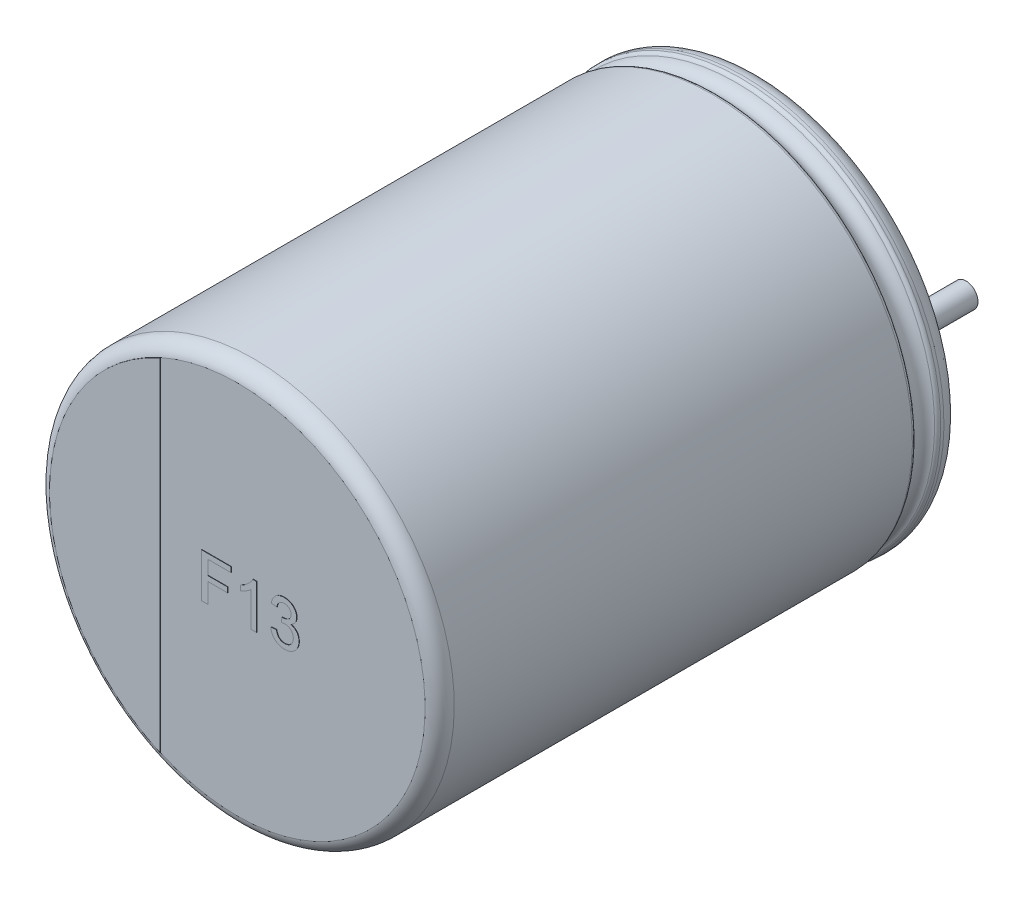
from build123d import *

# Parameters (mm, degrees)
SKETCH_2_R         = 0.3
EXTRUDE_1_DEPTH    = 2.7
EXTRUDE_2_DEPTH    = 0.01
EXTRUDE_1820_DEPTH = 0.01
EXTRUDE_5_DEPTH    = 0.05


with BuildPart() as part:
    # Sketch10 → Повернуть1 (revolve)
    with BuildSketch(Plane(origin=(0, 0, 0), x_dir=(0, 0, -1), z_dir=(1, 0, 0))):
        with BuildLine():
            Line((-13, 0), (-0.05, 0))
            Line((-0.05, 0), (-0.05, 4.403143426))
            ThreePointArc((-0.05, 4.403143426), (-0.052704561, 4.801565585), (-0.398206102, 5))
            Line((-0.398206102, 5), (-0.479422929, 5))
            ThreePointArc((-0.479422929, 5), (-0.534479696, 4.983479053), (-0.571344666, 4.939375046))
            ThreePointArc((-0.571344666, 4.939375046), (-0.831990181, 4.767472047), (-1.092635697, 4.939375046))
            ThreePointArc((-1.092635697, 4.939375046), (-1.129500666, 4.983479053), (-1.184557434, 5))
            Line((-1.184557434, 5), (-12.6, 5))
            ThreePointArc((-12.6, 5), (-12.85971595, 4.909961924), (-13, 4.67357323))
            Line((-13, 4.67357323), (-13, 0))
        make_face()
    revolve(axis=Axis((0, 0, -18.1630778), (0, 0, 1)))

    # Эскиз2 → Бобышка-Вытянуть1 (add)
    with BuildSketch(Plane(origin=(0, 0, 0.05), x_dir=(-1, 0, 0), z_dir=(0, 0, -1))):
        with Locations(Location((-2.5, 0, 0), (0, 0, 90))):
            Circle(SKETCH_2_R)
        with Locations(Location((2.5, 0, 0), (0, 0, 270))):
            Circle(SKETCH_2_R)
    extrude(amount=EXTRUDE_1_DEPTH)

    # Эскиз4 → Бобышка-Вытянуть2 (add)
    with BuildSketch(Plane.XY.offset(13)):
        with BuildLine():
            Line((-1.920580247, -4.260711003), (-1.920580247, 4.260711003))
            ThreePointArc((-1.920580247, 4.260711003), (-4.67357323, 0), (-1.920580247, -4.260711003))
        make_face()
    extrude(amount=EXTRUDE_2_DEPTH)

    # Эскиз5 → Extrude 1820 (add)
    with BuildSketch(Plane.XY.offset(13)):
        Polygon((-0.884369756, -0.464160183), (-0.884369756, 0.635839817), (-0.151036423, 0.635839817), (-0.151036423, 0.50891674), (-0.729241551, 0.50891674), (-0.729241551, 0.156352638), (-0.235651808, 0.156352638), (-0.235651808, 0.029429561), (-0.729241551, 0.029429561), (-0.729241551, -0.464160183), align=None)
        with BuildLine():
            Line((0.483578962, -0.464160183), (0.342553321, -0.464160183))
            Line((0.342553321, -0.464160183), (0.342553321, 0.393011291))
            add(Edge.make_bspline(
                [(0.342553321, 0.393011291), (0.334433052, 0.385180291), (0.317555963, 0.368904415), (0.289027027, 0.345869987), (0.257185088, 0.322523617), (0.222443635, 0.300073472), (0.187030601, 0.278939082), (0.152808462, 0.259931947), (0.120348573, 0.2438473), (0.098967068, 0.235052151), (0.088707167, 0.230831804)],
                knots=[0, 0, 0, 0, 0.893362401, 1.856755847, 2.901947673, 4.020460078, 5.132200827, 6.168787962, 7.121294059, 8, 8, 8, 8], degree=3))
            Line((0.088707167, 0.230831804), (0.088707167, 0.360839817))
            add(Edge.make_bspline(
                [(0.088707167, 0.360839817), (0.106329608, 0.369915409), (0.141062395, 0.387802865), (0.190132314, 0.418696959), (0.235944361, 0.452187428), (0.277740167, 0.488266859), (0.315207443, 0.525146514), (0.346781661, 0.562359534), (0.373200957, 0.598541851), (0.386456019, 0.623775005), (0.392793705, 0.635839817)],
                knots=[0, 0, 0, 0, 1.141258006, 2.249351951, 3.335817539, 4.406819942, 5.426913362, 6.360259544, 7.215985427, 8, 8, 8, 8], degree=3))
            Line((0.392793705, 0.635839817), (0.483578962, 0.635839817))
            Line((0.483578962, 0.635839817), (0.483578962, -0.464160183))
        make_face()
        with BuildLine():
            Line((0.836143064, -0.168006337), (0.977168705, -0.153903773))
            add(Edge.make_bspline(
                [(0.977168705, -0.153903773), (0.979048746, -0.162377428), (0.982686485, -0.178773324), (0.98968594, -0.202262147), (0.997078901, -0.224065027), (1.006243912, -0.243694287), (1.015186971, -0.261952681), (1.025696419, -0.278085789), (1.036925968, -0.292514547), (1.049083215, -0.305185376), (1.062308251, -0.316096508), (1.076424756, -0.325644336), (1.091731282, -0.333618059), (1.108110637, -0.339931304), (1.125424869, -0.345041929), (1.143768071, -0.348794569), (1.16323724, -0.351030063), (1.176581775, -0.351234784), (1.183418705, -0.35133967)],
                knots=[0, 0, 0, 0, 1.321063709, 2.556160278, 3.730472002, 4.821700466, 5.852032229, 6.822994757, 7.746964065, 8.632786469, 9.490489437, 10.352773447, 11.223141997, 12.11199479, 13.021433979, 13.96892724, 14.959401504, 16, 16, 16, 16], degree=3))
            add(Edge.make_bspline(
                [(1.183418705, -0.35133967), (1.191438182, -0.351225332), (1.207100233, -0.351002029), (1.229922425, -0.347651632), (1.251641766, -0.343051218), (1.271948377, -0.335837506), (1.291125017, -0.327021016), (1.309062437, -0.316125705), (1.325883416, -0.303331883), (1.341256172, -0.288552526), (1.35500399, -0.272294762), (1.367248354, -0.255122414), (1.377372798, -0.236888955), (1.385906179, -0.217851209), (1.392204931, -0.197701536), (1.396816125, -0.176691191), (1.399829565, -0.154725157), (1.400105037, -0.139737851), (1.400245628, -0.132088869)],
                knots=[0, 0, 0, 0, 1.111377895, 2.170522867, 3.193923215, 4.186422864, 5.152846954, 6.117443035, 7.091571248, 8.078879332, 9.069127402, 10.041602243, 10.999610288, 11.957618333, 12.930786866, 13.922135183, 14.939532534, 16, 16, 16, 16], degree=3))
            add(Edge.make_bspline(
                [(1.400245628, -0.132088869), (1.400080392, -0.124809694), (1.399757121, -0.11056857), (1.397099572, -0.089665655), (1.392462206, -0.06982315), (1.386033709, -0.050926221), (1.377819409, -0.033002608), (1.367946062, -0.015904101), (1.35587015, -5.414e-06), (1.342277646, 0.014864219), (1.327452189, 0.028563417), (1.311228004, 0.040216348), (1.294154064, 0.050273208), (1.276026886, 0.058393729), (1.256921736, 0.064839032), (1.236856826, 0.069471399), (1.215735689, 0.072130102), (1.201348232, 0.072453429), (1.193995628, 0.072618663)],
                knots=[0, 0, 0, 0, 1.072815875, 2.098878726, 3.09954706, 4.07199174, 5.036203424, 6.001873089, 6.97636515, 7.972747947, 8.969130744, 9.945905975, 10.911575641, 11.885646534, 12.868345115, 13.879560892, 14.916365174, 16, 16, 16, 16], degree=3))
            add(Edge.make_bspline(
                [(1.193995628, 0.072618663), (1.187522107, 0.072447159), (1.173783786, 0.072083188), (1.152100118, 0.068869458), (1.128081783, 0.064369483), (1.111484428, 0.059953425), (1.102769667, 0.057634689)],
                knots=[0, 0, 0, 0, 0.837610211, 1.777604146, 2.833088267, 4, 4, 4, 4], degree=3))
            Line((1.102769667, 0.057634689), (1.117312936, 0.184557766))
            add(Edge.make_bspline(
                [(1.117312936, 0.184557766), (1.12112875, 0.184140802), (1.127869979, 0.183404169), (1.134645204, 0.183132982), (1.137585372, 0.183015298)],
                knots=[0, 0, 0, 0, 1.132082448, 2, 2, 2, 2], degree=3))
            add(Edge.make_bspline(
                [(1.137585372, 0.183015298), (1.150555061, 0.183510476), (1.175997514, 0.184481859), (1.213087678, 0.192553238), (1.248238275, 0.205261365), (1.275394382, 0.220424003), (1.295532433, 0.234685288), (1.308231084, 0.24754386), (1.319679572, 0.261189402), (1.32822108, 0.276841333), (1.335600416, 0.293471887), (1.340170053, 0.311736188), (1.343502606, 0.331190275), (1.343722458, 0.344664705), (1.343835372, 0.351585009)],
                knots=[0, 0, 0, 0, 1.557468908, 3.055264441, 4.54122591, 6.035034992, 6.780215604, 7.498173296, 8.201377046, 8.913174237, 9.633083494, 10.382644491, 11.169345745, 12, 12, 12, 12], degree=3))
            add(Edge.make_bspline(
                [(1.343835372, 0.351585009), (1.343731161, 0.357174773), (1.343527354, 0.368106772), (1.341256851, 0.384134239), (1.337501717, 0.399320756), (1.332426281, 0.413828476), (1.325774418, 0.427581365), (1.317525585, 0.440562586), (1.308101014, 0.453035475), (1.296975642, 0.464355514), (1.285061333, 0.474983349), (1.271923622, 0.483934166), (1.258187765, 0.491885651), (1.243369331, 0.497894218), (1.227834152, 0.502834239), (1.21144943, 0.506296005), (1.194209186, 0.508620814), (1.182398379, 0.50881671), (1.176367423, 0.50891674)],
                knots=[0, 0, 0, 0, 1.041493611, 2.036867705, 3.009952345, 3.954088258, 4.897230656, 5.850851638, 6.817653571, 7.805463921, 8.805067469, 9.788883576, 10.763797054, 11.758134544, 12.762883247, 13.799594994, 14.876406454, 16, 16, 16, 16], degree=3))
            add(Edge.make_bspline(
                [(1.176367423, 0.50891674), (1.164564994, 0.508456544), (1.141772755, 0.507567837), (1.109140746, 0.499345454), (1.079570255, 0.486040568), (1.057677688, 0.470437651), (1.042132041, 0.45552038), (1.031513541, 0.442876273), (1.022015894, 0.42891349), (1.013612183, 0.413637011), (1.006415943, 0.396985397), (0.999928733, 0.379164938), (0.99490703, 0.359890328), (0.992503734, 0.346534924), (0.991271269, 0.339685971)],
                knots=[0, 0, 0, 0, 1.533565899, 2.961543033, 4.347411787, 5.731829577, 6.434842101, 7.147085226, 7.87612511, 8.629021686, 9.412189982, 10.234506416, 11.094615066, 12, 12, 12, 12], degree=3))
            Line((0.991271269, 0.339685971), (0.850245628, 0.353788535))
            add(Edge.make_bspline(
                [(0.850245628, 0.353788535), (0.85245169, 0.364692791), (0.856779055, 0.386082348), (0.865595305, 0.416974696), (0.876346613, 0.445973814), (0.889255365, 0.472946746), (0.90371171, 0.498216295), (0.920388154, 0.521482725), (0.938893715, 0.542884358), (0.959261266, 0.562355915), (0.981214304, 0.579746194), (1.004642259, 0.594747591), (1.029352865, 0.607463437), (1.055369259, 0.617714658), (1.08267084, 0.626050455), (1.111335282, 0.63157294), (1.141232839, 0.635308624), (1.161591856, 0.635660574), (1.171960372, 0.635839817)],
                knots=[0, 0, 0, 0, 1.136581168, 2.229493434, 3.279335563, 4.293305329, 5.282068175, 6.250623624, 7.213783178, 8.169396253, 9.125981663, 10.071280146, 11.007896369, 11.961295906, 12.925420184, 13.920544621, 14.940967302, 16, 16, 16, 16], degree=3))
            add(Edge.make_bspline(
                [(1.171960372, 0.635839817), (1.186312866, 0.635374401), (1.214534509, 0.634459243), (1.255985525, 0.627190944), (1.295633205, 0.61526352), (1.333158505, 0.598729984), (1.367915822, 0.578526439), (1.398673182, 0.554313721), (1.425019403, 0.526510705), (1.446442765, 0.495421358), (1.463407063, 0.462320493), (1.475960133, 0.42796036), (1.483460781, 0.392380513), (1.48439332, 0.368292965), (1.484861013, 0.356212413)],
                knots=[0, 0, 0, 0, 1.104647871, 2.172094857, 3.229560912, 4.285649672, 5.322588163, 6.317201348, 7.289435229, 8.260615662, 9.214246199, 10.146367077, 11.070353327, 12, 12, 12, 12], degree=3))
            add(Edge.make_bspline(
                [(1.484861013, 0.356212413), (1.484386866, 0.344792705), (1.483450685, 0.322245037), (1.476243196, 0.289276353), (1.464063975, 0.258042232), (1.447602241, 0.228433088), (1.42625541, 0.201089242), (1.400082117, 0.176723383), (1.369501065, 0.155102367), (1.346583153, 0.143848867), (1.334800917, 0.138063375)],
                knots=[0, 0, 0, 0, 0.975609618, 1.926294443, 2.868398979, 3.832526731, 4.812148358, 5.820404151, 6.879456693, 8, 8, 8, 8], degree=3))
            add(Edge.make_bspline(
                [(1.334800917, 0.138063375), (1.34270012, 0.136068982), (1.358172353, 0.132162549), (1.380393989, 0.124068531), (1.401284822, 0.114592471), (1.421122895, 0.103859719), (1.439332271, 0.091166499), (1.456540612, 0.077287902), (1.472097402, 0.061555526), (1.486453351, 0.044530099), (1.499515501, 0.026389796), (1.510507428, 0.006781747), (1.519993142, -0.013778587), (1.528081657, -0.035440329), (1.533894046, -0.058370507), (1.538050087, -0.082391482), (1.540792735, -0.107419796), (1.541110195, -0.124516158), (1.541271269, -0.133190632)],
                knots=[0, 0, 0, 0, 1.053251915, 2.063013066, 3.05373318, 4.018979697, 4.975584284, 5.920798056, 6.874756953, 7.832116109, 8.799604348, 9.761196922, 10.734637845, 11.72654167, 12.747371341, 13.789206138, 14.878271633, 16, 16, 16, 16], degree=3))
            add(Edge.make_bspline(
                [(1.541271269, -0.133190632), (1.541002861, -0.145033375), (1.540475351, -0.168308166), (1.535474547, -0.202499364), (1.52730211, -0.235259128), (1.515992554, -0.266698705), (1.501661556, -0.296946404), (1.483678518, -0.32557538), (1.462576415, -0.352818347), (1.43868515, -0.378414463), (1.412509982, -0.401938082), (1.384084752, -0.422307287), (1.353971849, -0.439605137), (1.322122271, -0.453711448), (1.288620449, -0.464794131), (1.253433057, -0.472738552), (1.216451207, -0.47740757), (1.191217936, -0.477973936), (1.178350596, -0.478262747)],
                knots=[0, 0, 0, 0, 1.016055063, 1.996874249, 2.958724482, 3.910019225, 4.860394196, 5.826121543, 6.806008102, 7.814207964, 8.82789325, 9.821757317, 10.810247154, 11.803791187, 12.806673825, 13.834534493, 14.895752369, 16, 16, 16, 16], degree=3))
            add(Edge.make_bspline(
                [(1.178350596, -0.478262747), (1.166803227, -0.478045241), (1.14407038, -0.477617047), (1.110794186, -0.47315599), (1.078913863, -0.466825238), (1.048681501, -0.457065622), (1.019745926, -0.445163929), (0.992597201, -0.429937507), (0.966747172, -0.412458166), (0.942681139, -0.392226514), (0.920532755, -0.36989606), (0.900773747, -0.345797089), (0.883806553, -0.319983108), (0.868846645, -0.292840343), (0.856755171, -0.263857141), (0.847340044, -0.23328234), (0.840160883, -0.201229412), (0.837496909, -0.17920119), (0.836143064, -0.168006337)],
                knots=[0, 0, 0, 0, 1.08471039, 2.135426191, 3.150939737, 4.135689946, 5.116584603, 6.086901885, 7.055842759, 8.045878862, 9.036901429, 10.008421467, 10.96965771, 11.936653536, 12.917548193, 13.915472582, 14.940632654, 16, 16, 16, 16], degree=3))
        make_face()
    extrude(amount=EXTRUDE_1820_DEPTH)

    # Эскиз6 → Бобышка-Вытянуть5 (add)
    with BuildSketch(Plane(origin=(0, 0, 0.05), x_dir=(-1, 0, 0), z_dir=(0, 0, -1))):
        with BuildLine():
            Line((-2.5, 0.624675577), (-2.607190564, 0.624675577))
            ThreePointArc((-2.607190564, 0.624675577), (-2.810142517, 0.728694397), (-2.844207888, 0.954191538))
            ThreePointArc((-2.844207888, 0.954191538), (0, 3), (2.844207888, 0.954191538))
            ThreePointArc((2.844207888, 0.954191538), (2.810142517, 0.728694397), (2.607190564, 0.624675577))
            Line((2.607190564, 0.624675577), (2.5, 0.624675577))
            ThreePointArc((2.5, 0.624675577), (1.875324423, 0), (2.5, -0.624675577))
            Line((2.5, -0.624675577), (2.607190564, -0.624675577))
            ThreePointArc((2.607190564, -0.624675577), (2.810142517, -0.728694397), (2.844207888, -0.954191538))
            ThreePointArc((2.844207888, -0.954191538), (0, -3), (-2.844207888, -0.954191538))
            ThreePointArc((-2.844207888, -0.954191538), (-2.810142517, -0.728694397), (-2.607190564, -0.624675577))
            Line((-2.607190564, -0.624675577), (-2.5, -0.624675577))
            ThreePointArc((-2.5, -0.624675577), (-1.875324423, 0), (-2.5, 0.624675577))
        make_face()
    extrude(amount=EXTRUDE_5_DEPTH)


solid = part.part
